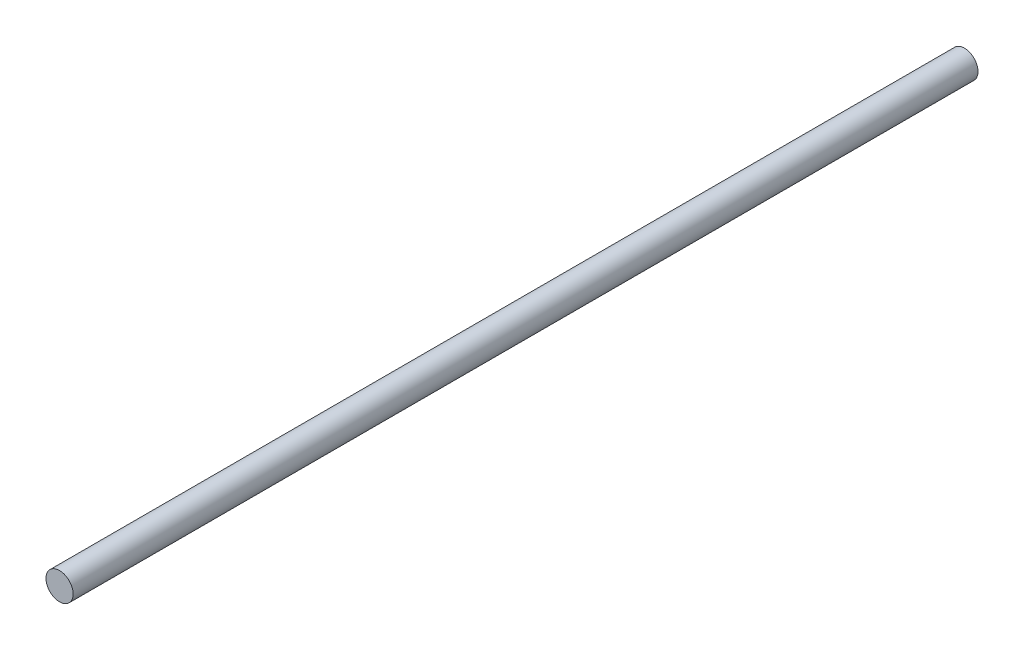
from build123d import *

# Parameters (mm, degrees)
SKETCH1_R           = 3
BOSS_EXTRUDE1_DEPTH = 200


with BuildPart() as part:
    # Sketch1 → Boss-Extrude1 (new body)
    with BuildSketch(Plane.XY):
        Circle(SKETCH1_R)
    extrude(amount=BOSS_EXTRUDE1_DEPTH)


solid = part.part
